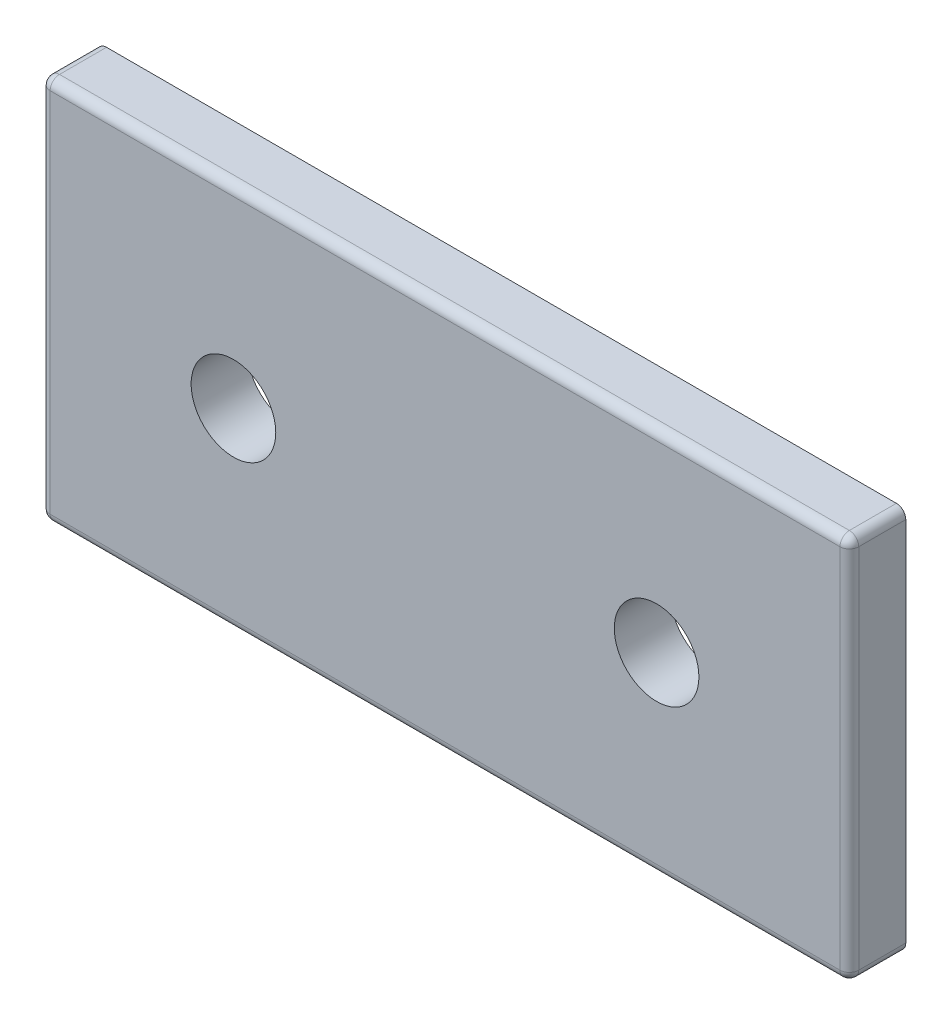
from build123d import *

# Parameters (mm, degrees)
SKETCH1_W           = 86
SKETCH1_H           = 41
SKETCH1_R           = 4.5
BOSS_EXTRUDE1_DEPTH = 3
FILLET1_R           = 1


with BuildPart() as part:
    # Sketch1 → Boss-Extrude1 (new body, symmetric)
    with BuildSketch(Plane.XY):
        with Locations((43, 20.5)):
            Rectangle(SKETCH1_W, SKETCH1_H)
        with Locations((20.5, 20.5)):
            Circle(SKETCH1_R, mode=Mode.SUBTRACT)
        with Locations((65.5, 20.5)):
            Circle(SKETCH1_R, mode=Mode.SUBTRACT)
    extrude(amount=BOSS_EXTRUDE1_DEPTH, both=True)

    # Fillet1
    fillet1_edges = [part.edges().sort_by_distance(p)[0] for p in [
        (43, 41, 3),
        (0, 20.5, 3),
        (43, 0, 3),
        (86, 20.5, 3),
        (0, 0, 0),
        (0, 41, 0),
        (86, 41, 0),
        (86, 0, 0),
    ]]
    fillet(fillet1_edges, radius=FILLET1_R)


solid = part.part
